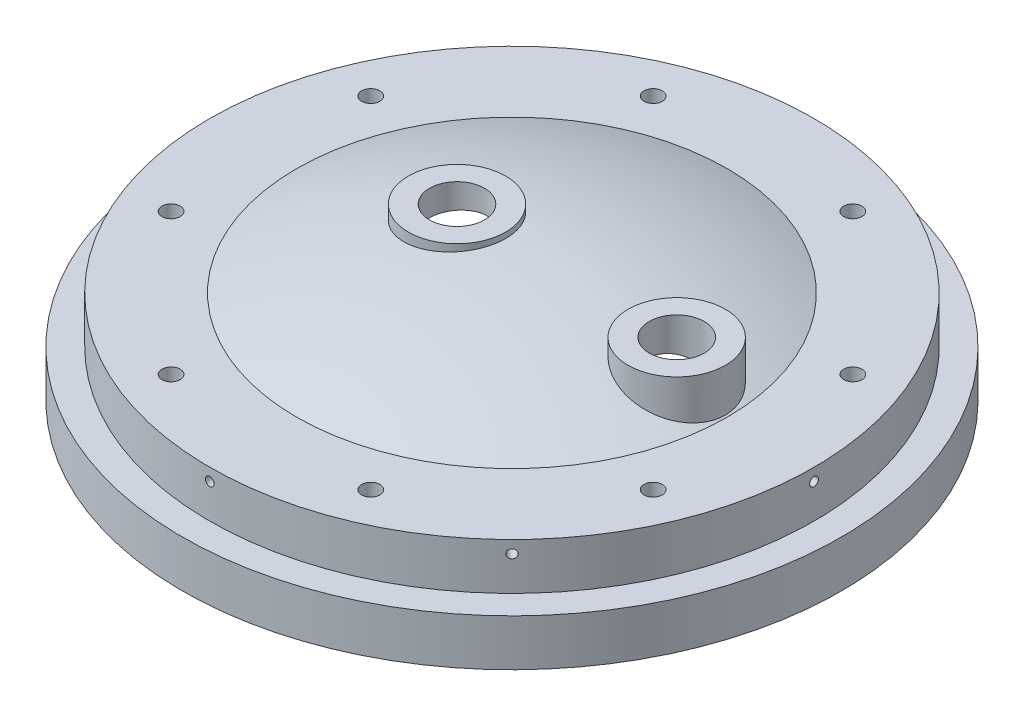
from build123d import *

# Parameters (mm, degrees)
CIRPATTERN1_COUNT               = 8
SKETCH6_R                       = 22.479
BOSS_EXTRUDE1_DEPTH             = 2.54
BOSS_EXTRUDE1_DIRECTION_2_REACH = 65.5
BOSS_EXTRUDE2_REACH             = 65.5
SKETCH7_R                       = 22.479
HOLE1_D                         = 25.4
HOLE1_DEPTH                     = 25.4
HOLE2_D                         = 25.4
HOLE2_DEPTH                     = 25.4
CIRPATTERN2_COUNT               = 8


with BuildPart() as part:
    # Sketch1 → Revolve1 (revolve)
    with BuildSketch(Plane.XY):
        with BuildLine():
            Line((146.05, 0), (152.4, 0))
            Line((152.4, 0), (152.4, 21.59))
            Line((152.4, 21.59), (139.7, 21.59))
            Line((139.7, 21.59), (139.7, 43.18))
            Line((139.7, 43.18), (99.547263147, 43.18))
            ThreePointArc((99.547263147, 43.18), (50.8, 58.368157867), (0, 63.5))
            Line((0, 63.5), (0, 57.15))
            ThreePointArc((0, 57.15), (76.813319255, 44.936268415), (146.05, 9.4998))
            Line((146.05, 9.4998), (146.05, 0))
        make_face()
    revolve(axis=Axis((0, 63.5, 0), (0, -1, 0)))

    # Sketch5 → Tap Drill for #10-32 Tap1 (revolve, cut)
    with BuildSketch(Plane(origin=(139.7, 37.465, 0), x_dir=(0, 0, -1), z_dir=(0, 1, 0))):
        Polygon((0, 0), (0, 11.373317848), (2.0193, 10.16), (2.0193, 0), align=None)
    tap_drill_for_10_32_tap1 = revolve(axis=Axis((146.05, 37.465, 0), (-1, 0, 0)), mode=Mode.SUBTRACT)

    # CirPattern1: Tap Drill for #10-32 Tap1 ×8 about axis
    cirpattern1_axis = Axis((0, 63.5, 0), (0, 1, 0))
    for i in range(1, CIRPATTERN1_COUNT):
        add(tap_drill_for_10_32_tap1.rotate(cirpattern1_axis, i * 360 / CIRPATTERN1_COUNT), mode=Mode.SUBTRACT)

    # Sketch6 → Boss-Extrude1 (add)
    with BuildSketch(Plane(origin=(0, 63.5, 0), x_dir=(1, 0, 0), z_dir=(0, 1, 0))):
        with Locations((-25.4, 0)):
            Circle(SKETCH6_R)
    extrude(amount=BOSS_EXTRUDE1_DEPTH)

    # Sketch6 → Boss-Extrude1 direction 2 (add, up to next)
    with BuildSketch(Plane(origin=(0, 63.5, 0), x_dir=(1, 0, 0), z_dir=(0, 1, 0)), mode=Mode.PRIVATE) as boss_extrude1_direction_2_sk1:
        with Locations((-25.4, 0)):
            Circle(SKETCH6_R)
    boss_extrude1_direction_2_tool1 = extrude(boss_extrude1_direction_2_sk1.sketch, amount=-BOSS_EXTRUDE1_DIRECTION_2_REACH, mode=Mode.PRIVATE) - part.part
    add(boss_extrude1_direction_2_tool1.solids().sort_by_distance((-25.4, 63.5, 0))[0])

    # Sketch7 → Boss-Extrude2 (add, up to next)
    with BuildSketch(Plane(origin=(0, 63.5, 0), x_dir=(1, 0, 0), z_dir=(0, 1, 0)), mode=Mode.PRIVATE) as boss_extrude2_sk1:
        with Locations((76.2, 0)):
            Circle(SKETCH7_R)
    boss_extrude2_tool1 = extrude(boss_extrude2_sk1.sketch, amount=-BOSS_EXTRUDE2_REACH, mode=Mode.PRIVATE) - part.part
    add(boss_extrude2_tool1.solids().sort_by_distance((76.2, 63.5, 0))[0])

    # Hole1
    with Locations(Plane(origin=(0, 66.04, 0), x_dir=(1, 0, 0), z_dir=(0, 1, 0))):
        with Locations((-25.4, 0)):
            Hole(HOLE1_D / 2, depth=HOLE1_DEPTH)

    # Hole2
    with Locations(Plane(origin=(0, 63.5, 0), x_dir=(1, 0, 0), z_dir=(0, 1, 0))):
        with Locations((76.2, 0)):
            Hole(HOLE2_D / 2, depth=HOLE2_DEPTH)

    # Sketch16 → 3/8-24 Tapped Hole1 (revolve, cut)
    with BuildSketch(Plane(origin=(111.466065597, 43.18, -46.170756115), x_dir=(0, 0, 1), z_dir=(1, 0, 0))):
        Polygon((0, 0), (0, 12.185468714), (4.2164, 9.652), (4.2164, 0), align=None)
    f_3_8_24_tapped_hole1 = revolve(axis=Axis((111.466065597, 49.53, -46.170756115), (0, -1, 0)), mode=Mode.SUBTRACT)

    # CirPattern2: 3/8-24 Tapped Hole1 ×8 about axis
    cirpattern2_axis = Axis((0, 0, 0), (0, 1, 0))
    for i in range(1, CIRPATTERN2_COUNT):
        add(f_3_8_24_tapped_hole1.rotate(cirpattern2_axis, i * 360 / CIRPATTERN2_COUNT), mode=Mode.SUBTRACT)


solid = part.part
